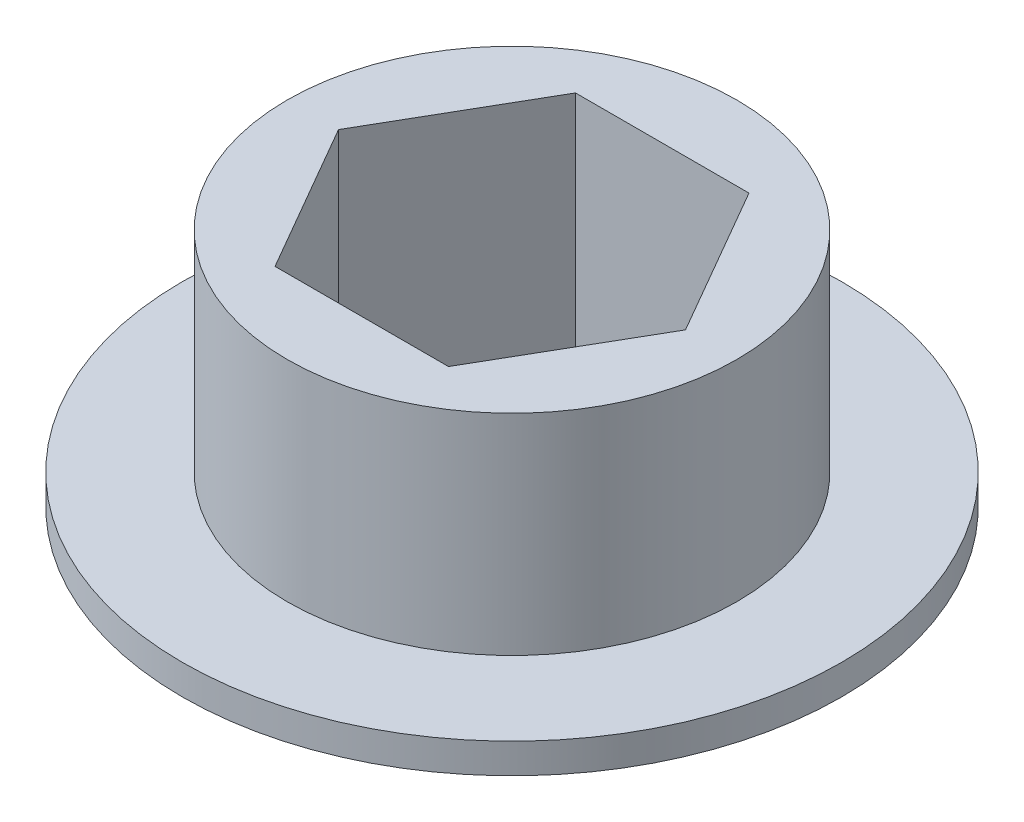
from build123d import *

# Parameters (mm, degrees)
SKETCH1_R           = 7.5
BOSS_EXTRUDE1_DEPTH = 4
BOSS_EXTRUDE2_START = -1
SKETCH2_R           = 11
SKETCH2_R_2         = 7.5
BOSS_EXTRUDE2_DEPTH = 1


with BuildPart() as part:
    # Sketch1 → Boss-Extrude1 (new, symmetric)
    with BuildSketch(Plane(origin=(0, 0, 0), x_dir=(1, 0, 0), z_dir=(0, 1, 0))):
        Circle(SKETCH1_R)
        Polygon((-2.893968224, -5.0125), (2.893968224, -5.0125), (5.787936449, 0), (2.893968224, 5.0125), (-2.893968224, 5.0125), (-5.787936449, 0), align=None, mode=Mode.SUBTRACT)
    extrude(amount=BOSS_EXTRUDE1_DEPTH, both=True)

    # Sketch2 → Boss-Extrude2 (add)
    with BuildSketch(Plane.XZ.offset(4).offset(BOSS_EXTRUDE2_START)):
        Circle(SKETCH2_R)
        Circle(SKETCH2_R_2, mode=Mode.SUBTRACT)
    extrude(amount=BOSS_EXTRUDE2_DEPTH)


solid = part.part
